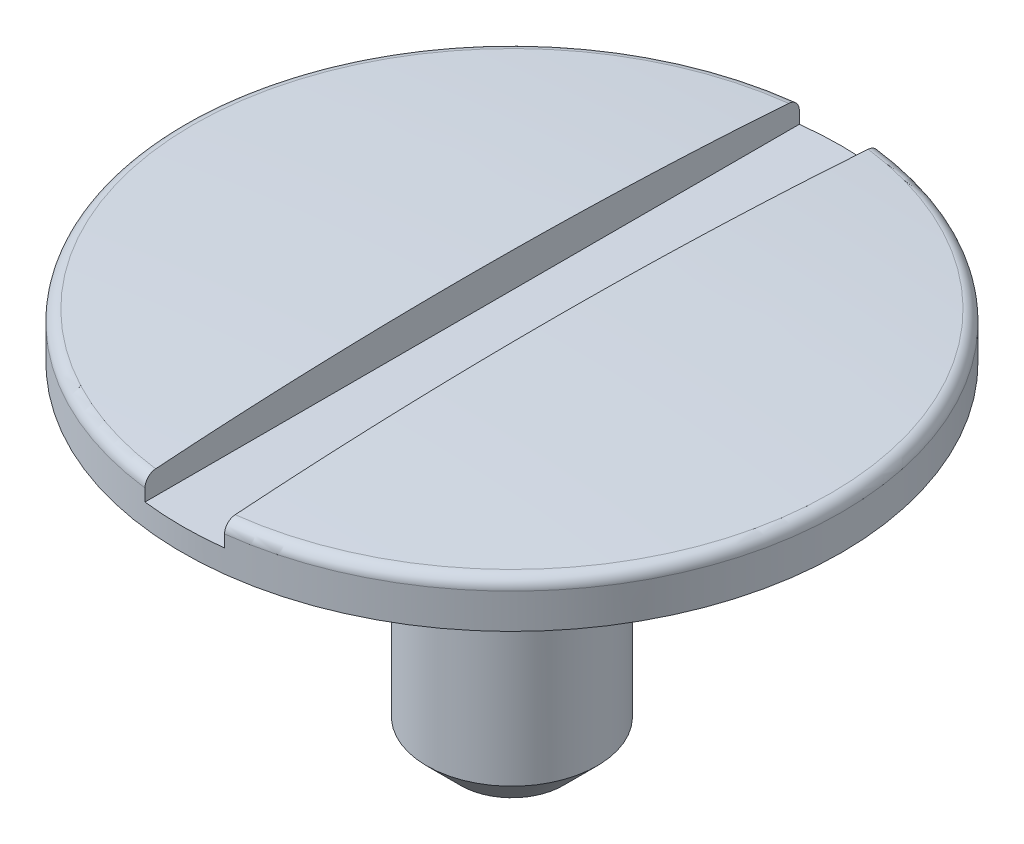
from build123d import *

# Parameters (mm, degrees)
SKETCH2_R               = 0.375
BOSS_EXTRUDE2_DEPTH     = 1.5
FILLET1_R               = 0.05
CHAMFER2_SIZE           = 0.15
CUT_EXTRUDE1_DEPTH      = 2.4500001
CUT_EXTRUDE1_DEPTH_BACK = 2.4500001


with BuildPart() as part:
    # Sketch4 → Revolve1 (revolve)
    with BuildSketch(Plane.XY):
        with BuildLine():
            Line((0, 0), (1.45, 0))
            Line((1.45, 0), (1.45, 0.2))
            ThreePointArc((1.45, 0.2), (0.725477446, 0.239469483), (0, 0.252631753))
            Line((0, 0.252631753), (0, 0))
        make_face()
    revolve(axis=Axis((0, -848.356227188, 0), (0, 1, 0)))

    # Sketch2 → Boss-Extrude2 (add)
    with BuildSketch(Plane(origin=(0, 0, 0), x_dir=(1, 0, 0), z_dir=(0, 1, 0))):
        Circle(SKETCH2_R)
    extrude(amount=-BOSS_EXTRUDE2_DEPTH)

    # Fillet1
    fillet1_edges = [part.edges().sort_by_distance(p)[0] for p in [
        (-1.45, 0.2, 0),
    ]]
    fillet(fillet1_edges, radius=FILLET1_R)

    # Chamfer2
    chamfer2_edges = [part.edges().sort_by_distance(p)[0] for p in [
        (-0.375, -1.5, 0),
    ]]
    chamfer(chamfer2_edges, length=CHAMFER2_SIZE)

    # Sketch3 → Cut-Extrude1 (cut, two sides)
    with BuildSketch(Plane.XY) as cut_extrude1_sk:
        Polygon((-0.175, 0.35), (0, 0.35), (0.175, 0.35), (0.175, 0.1), (0, 0.1), (-0.175, 0.1), align=None)
    extrude(amount=CUT_EXTRUDE1_DEPTH, mode=Mode.SUBTRACT)
    extrude(cut_extrude1_sk.sketch, amount=-CUT_EXTRUDE1_DEPTH_BACK, mode=Mode.SUBTRACT)


solid = part.part
